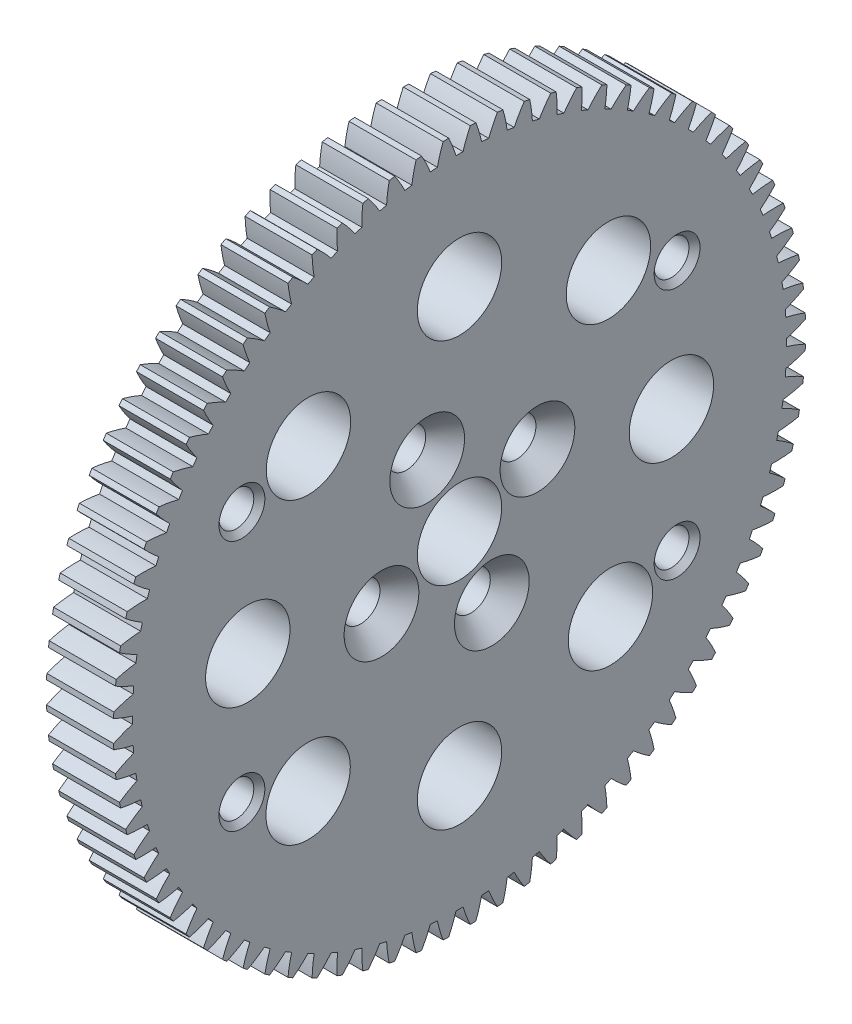
from build123d import *

# Parameters (mm, degrees)
SKETCH1_R                                      = 4
SKETCH1_R_2                                    = 1.75
BOSS_EXTRUDE1_DEPTH                            = 3.175
M4X0_7_TAPPED_HOLE1_AT_2_COUNT                 = 2
M4X0_7_TAPPED_HOLE1_AT_2_PITCH                 = 23.8125
M4X0_7_TAPPED_HOLE1_AT_3_COUNT                 = 2
M4X0_7_TAPPED_HOLE1_AT_3_PITCH                 = 41.244459855
M4X0_7_TAPPED_HOLE1_AT_4_COUNT                 = 2
M4X0_7_TAPPED_HOLE1_AT_4_PITCH                 = 47.625
CSK_FOR_6_FLAT_HEAD_MACHINE_SCREW1_D           = 3.6576
CSK_FOR_6_FLAT_HEAD_MACHINE_SCREW1_CSINK_D     = 7.0866
CSK_FOR_6_FLAT_HEAD_MACHINE_SCREW1_CSINK_ANGLE = 82


with BuildPart() as part:
    # Sketch1 → Boss-Extrude1 (new, symmetric)
    with BuildSketch(Plane(origin=(0, 0, 0), x_dir=(0, -1, 0), z_dir=(-1, 0, 0))):
        with BuildLine():
            ThreePointArc((-32.540485036, -4.117867604), (-31.611759802, -4.35271874), (-30.668071435, -4.517454533))
            ThreePointArc((-30.668071435, -4.517454533), (-30.61735087, -4.849311982), (-30.563039402, -5.180600688))
            ThreePointArc((-30.563039402, -5.180600688), (-31.409634214, -5.62888948), (-32.220331407, -6.139238063))
            ThreePointArc((-32.220331407, -6.139238063), (-32.169757197, -6.398962562), (-32.117089412, -6.658270623))
            ThreePointArc((-32.117089412, -6.658270623), (-31.17280092, -6.819530849), (-30.219096608, -6.909717881))
            ThreePointArc((-30.219096608, -6.909717881), (-30.142495162, -7.236572834), (-30.062358507, -7.562579059))
            ThreePointArc((-30.062358507, -7.562579059), (-30.871171216, -8.075908989), (-31.639327812, -8.648290907))
            ThreePointArc((-31.639327812, -8.648290907), (-31.568531756, -8.903246756), (-31.495681252, -9.15762319))
            ThreePointArc((-31.495681252, -9.15762319), (-30.541651355, -9.244298283), (-29.583811002, -9.25938052))
            ThreePointArc((-29.583811002, -9.25938052), (-29.481800949, -9.579217809), (-29.376333174, -9.897931615))
            ThreePointArc((-29.376333174, -9.897931615), (-30.142377181, -10.473137835), (-30.863257239, -11.104024162))
            ThreePointArc((-30.863257239, -11.104024162), (-30.772675818, -11.352639472), (-30.680091743, -11.600515964))
            ThreePointArc((-30.680091743, -11.600515964), (-29.722202353, -11.612071544), (-28.766131363, -11.551955999))
            ThreePointArc((-28.766131363, -11.551955999), (-28.639341628, -11.86280372), (-28.509192978, -12.172260132))
            ThreePointArc((-28.509192978, -12.172260132), (-29.227745368, -12.805796303), (-29.896904422, -13.491297415))
            ThreePointArc((-29.896904422, -13.491297415), (-29.787096101, -13.732039391), (-29.675349267, -13.9718877))
            ThreePointArc((-29.675349267, -13.9718877), (-28.719506089, -13.908252522), (-27.771098959, -13.773309829))
            ThreePointArc((-27.771098959, -13.773309829), (-27.620311243, -14.073251501), (-27.466284128, -14.371542617))
            ThreePointArc((-27.466284128, -14.371542617), (-28.132914785, -15.059502778), (-28.746227248, -15.795392334))
            ThreePointArc((-28.746227248, -15.795392334), (-28.617869032, -16.026776721), (-28.487648394, -16.257118102))
            ThreePointArc((-28.487648394, -16.257118102), (-27.53974452, -16.118684499), (-26.604848494, -15.909746623))
            ThreePointArc((-26.604848494, -15.909746623), (-26.430992455, -16.196933008), (-26.254036502, -16.482219763))
            ThreePointArc((-26.254036502, -16.482219763), (-26.864635428, -17.220362411), (-27.418320024, -18.002103406))
            ThreePointArc((-27.418320024, -18.002103406), (-27.272203284, -18.222703643), (-27.124311696, -18.442117965))
            ThreePointArc((-27.124311696, -18.442117965), (-26.190191269, -18.229739426), (-25.274570292, -17.948094538))
            ThreePointArc((-25.274570292, -17.948094538), (-25.078717809, -18.220755036), (-24.879924011, -18.491278544))
            ThreePointArc((-24.879924011, -18.491278544), (-25.430726659, -19.275052784), (-25.921369739, -20.097825525))
            ThreePointArc((-25.921369739, -20.097825525), (-25.758395333, -20.306281537), (-25.593744596, -20.513416038))
            ThreePointArc((-25.593744596, -20.513416038), (-24.679166779, -20.228401947), (-23.788465959, -19.875786483))
            ThreePointArc((-23.788465959, -19.875786483), (-23.571824528, -20.13224005), (-23.352418516, -20.386332443))
            ThreePointArc((-23.352418516, -20.386332443), (-23.840029005, -21.210906046), (-24.26460559, -22.069637866))
            ThreePointArc((-24.26460559, -22.069637866), (-24.085778309, -22.264664453), (-23.905383551, -22.458242079))
            ThreePointArc((-23.905383551, -22.458242079), (-23.015987019, -22.102349643), (-22.155697823, -21.680937594))
            ThreePointArc((-22.155697823, -21.680937594), (-21.91960311, -21.91960311), (-21.680937594, -22.155697823))
            ThreePointArc((-21.680937594, -22.155697823), (-22.102349643, -23.015987019), (-22.458242079, -23.905383551))
            ThreePointArc((-22.458242079, -23.905383551), (-22.264664453, -24.085778309), (-22.069637866, -24.26460559))
            ThreePointArc((-22.069637866, -24.26460559), (-21.210906046, -23.840029005), (-20.386332443, -23.352418516))
            ThreePointArc((-20.386332443, -23.352418516), (-20.13224005, -23.571824528), (-19.875786483, -23.788465959))
            ThreePointArc((-19.875786483, -23.788465959), (-20.228401947, -24.679166779), (-20.513416038, -25.593744596))
            ThreePointArc((-20.513416038, -25.593744596), (-20.306281537, -25.758395333), (-20.097825525, -25.921369739))
            ThreePointArc((-20.097825525, -25.921369739), (-19.275052784, -25.430726659), (-18.491278544, -24.879924011))
            ThreePointArc((-18.491278544, -24.879924011), (-18.220755036, -25.078717809), (-17.948094538, -25.274570292))
            ThreePointArc((-17.948094538, -25.274570292), (-18.229739426, -26.190191269), (-18.442117965, -27.124311696))
            ThreePointArc((-18.442117965, -27.124311696), (-18.222703643, -27.272203284), (-18.002103406, -27.418320024))
            ThreePointArc((-18.002103406, -27.418320024), (-17.220362411, -26.864635428), (-16.482219763, -26.254036502))
            ThreePointArc((-16.482219763, -26.254036502), (-16.196933008, -26.430992455), (-15.909746623, -26.604848494))
            ThreePointArc((-15.909746623, -26.604848494), (-16.118684499, -27.53974452), (-16.257118102, -28.487648394))
            ThreePointArc((-16.257118102, -28.487648394), (-16.026776721, -28.617869032), (-15.795392334, -28.746227248))
            ThreePointArc((-15.795392334, -28.746227248), (-15.059502778, -28.132914785), (-14.371542617, -27.466284128))
            ThreePointArc((-14.371542617, -27.466284128), (-14.073251501, -27.620311243), (-13.773309829, -27.771098959))
            ThreePointArc((-13.773309829, -27.771098959), (-13.908252522, -28.719506089), (-13.9718877, -29.675349267))
            ThreePointArc((-13.9718877, -29.675349267), (-13.732039391, -29.787096101), (-13.491297415, -29.896904422))
            ThreePointArc((-13.491297415, -29.896904422), (-12.805796303, -29.227745368), (-12.172260132, -28.509192978))
            ThreePointArc((-12.172260132, -28.509192978), (-11.86280372, -28.639341628), (-11.551955999, -28.766131363))
            ThreePointArc((-11.551955999, -28.766131363), (-11.612071544, -29.722202353), (-11.600515964, -30.680091743))
            ThreePointArc((-11.600515964, -30.680091743), (-11.352639472, -30.772675818), (-11.104024162, -30.863257239))
            ThreePointArc((-11.104024162, -30.863257239), (-10.473137835, -30.142377181), (-9.897931615, -29.376333174))
            ThreePointArc((-9.897931615, -29.376333174), (-9.579217809, -29.481800949), (-9.25938052, -29.583811002))
            ThreePointArc((-9.25938052, -29.583811002), (-9.244298283, -30.541651355), (-9.15762319, -31.495681252))
            ThreePointArc((-9.15762319, -31.495681252), (-8.903246756, -31.568531756), (-8.648290907, -31.639327812))
            ThreePointArc((-8.648290907, -31.639327812), (-8.075908989, -30.871171216), (-7.562579059, -30.062358507))
            ThreePointArc((-7.562579059, -30.062358507), (-7.236572834, -30.142495162), (-6.909717881, -30.219096608))
            ThreePointArc((-6.909717881, -30.219096608), (-6.819530849, -31.17280092), (-6.658270623, -32.117089412))
            ThreePointArc((-6.658270623, -32.117089412), (-6.398962562, -32.169757197), (-6.139238063, -32.220331407))
            ThreePointArc((-6.139238063, -32.220331407), (-5.62888948, -31.409634214), (-5.180600688, -30.563039402))
            ThreePointArc((-5.180600688, -30.563039402), (-4.849311982, -30.61735087), (-4.517454533, -30.668071435))
            ThreePointArc((-4.517454533, -30.668071435), (-4.35271874, -31.611759802), (-4.117867604, -32.540485036))
            ThreePointArc((-4.117867604, -32.540485036), (-3.855226637, -32.572645388), (-3.592334775, -32.602685946))
            ThreePointArc((-3.592334775, -32.602685946), (-3.147165994, -31.754446373), (-2.76668219, -30.875288997))
            ThreePointArc((-2.76668219, -30.875288997), (-2.432153508, -30.903440428), (-2.097339576, -30.927967403))
            ThreePointArc((-2.097339576, -30.927967403), (-1.859070673, -31.855821673), (-1.552076562, -32.763257749))
            ThreePointArc((-1.552076562, -32.763257749), (-1.287721957, -32.774712389), (-1.023283548, -32.784034083))
            ThreePointArc((-1.023283548, -32.784034083), (-0.646039184, -31.90348181), (-0.335706178, -30.997182168))
            ThreePointArc((-0.335706178, -30.997182168), (0, -30.999), (0.335706178, -30.997182168))
            ThreePointArc((0.335706178, -30.997182168), (0.646039184, -31.90348181), (1.023283548, -32.784034083))
            ThreePointArc((1.023283548, -32.784034083), (1.287721957, -32.774712389), (1.552076562, -32.763257749))
            ThreePointArc((1.552076562, -32.763257749), (1.859070673, -31.855821673), (2.097339576, -30.927967403))
            ThreePointArc((2.097339576, -30.927967403), (2.432153508, -30.903440428), (2.76668219, -30.875288997))
            ThreePointArc((2.76668219, -30.875288997), (3.147165994, -31.754446373), (3.592334775, -32.602685946))
            ThreePointArc((3.592334775, -32.602685946), (3.855226637, -32.572645388), (4.117867604, -32.540485036))
            ThreePointArc((4.117867604, -32.540485036), (4.35271874, -31.611759802), (4.517454533, -30.668071435))
            ThreePointArc((4.517454533, -30.668071435), (4.849311982, -30.61735087), (5.180600688, -30.563039402))
            ThreePointArc((5.180600688, -30.563039402), (5.62888948, -31.409634214), (6.139238063, -32.220331407))
            ThreePointArc((6.139238063, -32.220331407), (6.398962562, -32.169757197), (6.658270623, -32.117089412))
            ThreePointArc((6.658270623, -32.117089412), (6.819530849, -31.17280092), (6.909717881, -30.219096608))
            ThreePointArc((6.909717881, -30.219096608), (7.236572834, -30.142495162), (7.562579059, -30.062358507))
            ThreePointArc((7.562579059, -30.062358507), (8.075908989, -30.871171216), (8.648290907, -31.639327812))
            ThreePointArc((8.648290907, -31.639327812), (8.903246756, -31.568531756), (9.15762319, -31.495681252))
            ThreePointArc((9.15762319, -31.495681252), (9.244298283, -30.541651355), (9.25938052, -29.583811002))
            ThreePointArc((9.25938052, -29.583811002), (9.579217809, -29.481800949), (9.897931615, -29.376333174))
            ThreePointArc((9.897931615, -29.376333174), (10.473137835, -30.142377181), (11.104024162, -30.863257239))
            ThreePointArc((11.104024162, -30.863257239), (11.352639472, -30.772675818), (11.600515964, -30.680091743))
            ThreePointArc((11.600515964, -30.680091743), (11.612071544, -29.722202353), (11.551955999, -28.766131363))
            ThreePointArc((11.551955999, -28.766131363), (11.86280372, -28.639341628), (12.172260132, -28.509192978))
            ThreePointArc((12.172260132, -28.509192978), (12.805796303, -29.227745368), (13.491297415, -29.896904422))
            ThreePointArc((13.491297415, -29.896904422), (13.732039391, -29.787096101), (13.9718877, -29.675349267))
            ThreePointArc((13.9718877, -29.675349267), (13.908252522, -28.719506089), (13.773309829, -27.771098959))
            ThreePointArc((13.773309829, -27.771098959), (14.073251501, -27.620311243), (14.371542617, -27.466284128))
            ThreePointArc((14.371542617, -27.466284128), (15.059502778, -28.132914785), (15.795392334, -28.746227248))
            ThreePointArc((15.795392334, -28.746227248), (16.026776721, -28.617869032), (16.257118102, -28.487648394))
            ThreePointArc((16.257118102, -28.487648394), (16.118684499, -27.53974452), (15.909746623, -26.604848494))
            ThreePointArc((15.909746623, -26.604848494), (16.196933008, -26.430992455), (16.482219763, -26.254036502))
            ThreePointArc((16.482219763, -26.254036502), (17.220362411, -26.864635428), (18.002103406, -27.418320024))
            ThreePointArc((18.002103406, -27.418320024), (18.222703643, -27.272203284), (18.442117965, -27.124311696))
            ThreePointArc((18.442117965, -27.124311696), (18.229739426, -26.190191269), (17.948094538, -25.274570292))
            ThreePointArc((17.948094538, -25.274570292), (18.220755036, -25.078717809), (18.491278544, -24.879924011))
            ThreePointArc((18.491278544, -24.879924011), (19.275052784, -25.430726659), (20.097825525, -25.921369739))
            ThreePointArc((20.097825525, -25.921369739), (20.306281537, -25.758395333), (20.513416038, -25.593744596))
            ThreePointArc((20.513416038, -25.593744596), (20.228401947, -24.679166779), (19.875786483, -23.788465959))
            ThreePointArc((19.875786483, -23.788465959), (20.13224005, -23.571824528), (20.386332443, -23.352418516))
            ThreePointArc((20.386332443, -23.352418516), (21.210906046, -23.840029005), (22.069637866, -24.26460559))
            ThreePointArc((22.069637866, -24.26460559), (22.264664453, -24.085778309), (22.458242079, -23.905383551))
            ThreePointArc((22.458242079, -23.905383551), (22.102349643, -23.015987019), (21.680937594, -22.155697823))
            ThreePointArc((21.680937594, -22.155697823), (21.91960311, -21.91960311), (22.155697823, -21.680937594))
            ThreePointArc((22.155697823, -21.680937594), (23.015987019, -22.102349643), (23.905383551, -22.458242079))
            ThreePointArc((23.905383551, -22.458242079), (24.085778309, -22.264664453), (24.26460559, -22.069637866))
            ThreePointArc((24.26460559, -22.069637866), (23.840029005, -21.210906046), (23.352418516, -20.386332443))
            ThreePointArc((23.352418516, -20.386332443), (23.571824528, -20.13224005), (23.788465959, -19.875786483))
            ThreePointArc((23.788465959, -19.875786483), (24.679166779, -20.228401947), (25.593744596, -20.513416038))
            ThreePointArc((25.593744596, -20.513416038), (25.758395333, -20.306281537), (25.921369739, -20.097825525))
            ThreePointArc((25.921369739, -20.097825525), (25.430726659, -19.275052784), (24.879924011, -18.491278544))
            ThreePointArc((24.879924011, -18.491278544), (25.078717809, -18.220755036), (25.274570292, -17.948094538))
            ThreePointArc((25.274570292, -17.948094538), (26.190191269, -18.229739426), (27.124311696, -18.442117965))
            ThreePointArc((27.124311696, -18.442117965), (27.272203284, -18.222703643), (27.418320024, -18.002103406))
            ThreePointArc((27.418320024, -18.002103406), (26.864635428, -17.220362411), (26.254036502, -16.482219763))
            ThreePointArc((26.254036502, -16.482219763), (26.430992455, -16.196933008), (26.604848494, -15.909746623))
            ThreePointArc((26.604848494, -15.909746623), (27.53974452, -16.118684499), (28.487648394, -16.257118102))
            ThreePointArc((28.487648394, -16.257118102), (28.617869032, -16.026776721), (28.746227248, -15.795392334))
            ThreePointArc((28.746227248, -15.795392334), (28.132914785, -15.059502778), (27.466284128, -14.371542617))
            ThreePointArc((27.466284128, -14.371542617), (27.620311243, -14.073251501), (27.771098959, -13.773309829))
            ThreePointArc((27.771098959, -13.773309829), (28.719506089, -13.908252522), (29.675349267, -13.9718877))
            ThreePointArc((29.675349267, -13.9718877), (29.787096101, -13.732039391), (29.896904422, -13.491297415))
            ThreePointArc((29.896904422, -13.491297415), (29.227745368, -12.805796303), (28.509192978, -12.172260132))
            ThreePointArc((28.509192978, -12.172260132), (28.639341628, -11.86280372), (28.766131363, -11.551955999))
            ThreePointArc((28.766131363, -11.551955999), (29.722202353, -11.612071544), (30.680091743, -11.600515964))
            ThreePointArc((30.680091743, -11.600515964), (30.772675818, -11.352639472), (30.863257239, -11.104024162))
            ThreePointArc((30.863257239, -11.104024162), (30.142377181, -10.473137835), (29.376333174, -9.897931615))
            ThreePointArc((29.376333174, -9.897931615), (29.481800949, -9.579217809), (29.583811002, -9.25938052))
            ThreePointArc((29.583811002, -9.25938052), (30.541651355, -9.244298283), (31.495681252, -9.15762319))
            ThreePointArc((31.495681252, -9.15762319), (31.568531756, -8.903246756), (31.639327812, -8.648290907))
            ThreePointArc((31.639327812, -8.648290907), (30.871171216, -8.075908989), (30.062358507, -7.562579059))
            ThreePointArc((30.062358507, -7.562579059), (30.142495162, -7.236572834), (30.219096608, -6.909717881))
            ThreePointArc((30.219096608, -6.909717881), (31.17280092, -6.819530849), (32.117089412, -6.658270623))
            ThreePointArc((32.117089412, -6.658270623), (32.169757197, -6.398962562), (32.220331407, -6.139238063))
            ThreePointArc((32.220331407, -6.139238063), (31.409634214, -5.62888948), (30.563039402, -5.180600688))
            ThreePointArc((30.563039402, -5.180600688), (30.61735087, -4.849311982), (30.668071435, -4.517454533))
            ThreePointArc((30.668071435, -4.517454533), (31.611759802, -4.35271874), (32.540485036, -4.117867604))
            ThreePointArc((32.540485036, -4.117867604), (32.572645388, -3.855226637), (32.602685946, -3.592334775))
            ThreePointArc((32.602685946, -3.592334775), (31.754446373, -3.147165994), (30.875288997, -2.76668219))
            ThreePointArc((30.875288997, -2.76668219), (30.903440428, -2.432153508), (30.927967403, -2.097339576))
            ThreePointArc((30.927967403, -2.097339576), (31.855821673, -1.859070673), (32.763257749, -1.552076562))
            ThreePointArc((32.763257749, -1.552076562), (32.774712389, -1.287721957), (32.784034083, -1.023283548))
            ThreePointArc((32.784034083, -1.023283548), (31.90348181, -0.646039184), (30.997182168, -0.335706178))
            ThreePointArc((30.997182168, -0.335706178), (30.999, 0), (30.997182168, 0.335706178))
            ThreePointArc((30.997182168, 0.335706178), (31.90348181, 0.646039184), (32.784034083, 1.023283548))
            ThreePointArc((32.784034083, 1.023283548), (32.774712389, 1.287721957), (32.763257749, 1.552076562))
            ThreePointArc((32.763257749, 1.552076562), (31.855821673, 1.859070673), (30.927967403, 2.097339576))
            ThreePointArc((30.927967403, 2.097339576), (30.903440428, 2.432153508), (30.875288997, 2.76668219))
            ThreePointArc((30.875288997, 2.76668219), (31.754446373, 3.147165994), (32.602685946, 3.592334775))
            ThreePointArc((32.602685946, 3.592334775), (32.572645388, 3.855226637), (32.540485036, 4.117867604))
            ThreePointArc((32.540485036, 4.117867604), (31.611759802, 4.35271874), (30.668071435, 4.517454533))
            ThreePointArc((30.668071435, 4.517454533), (30.61735087, 4.849311982), (30.563039402, 5.180600688))
            ThreePointArc((30.563039402, 5.180600688), (31.409634214, 5.62888948), (32.220331407, 6.139238063))
            ThreePointArc((32.220331407, 6.139238063), (32.169757197, 6.398962562), (32.117089412, 6.658270623))
            ThreePointArc((32.117089412, 6.658270623), (31.17280092, 6.819530849), (30.219096608, 6.909717881))
            ThreePointArc((30.219096608, 6.909717881), (30.142495162, 7.236572834), (30.062358507, 7.562579059))
            ThreePointArc((30.062358507, 7.562579059), (30.871171216, 8.075908989), (31.639327812, 8.648290907))
            ThreePointArc((31.639327812, 8.648290907), (31.568531756, 8.903246756), (31.495681252, 9.15762319))
            ThreePointArc((31.495681252, 9.15762319), (30.541651355, 9.244298283), (29.583811002, 9.25938052))
            ThreePointArc((29.583811002, 9.25938052), (29.481800949, 9.579217809), (29.376333174, 9.897931615))
            ThreePointArc((29.376333174, 9.897931615), (30.142377181, 10.473137835), (30.863257239, 11.104024162))
            ThreePointArc((30.863257239, 11.104024162), (30.772675818, 11.352639472), (30.680091743, 11.600515964))
            ThreePointArc((30.680091743, 11.600515964), (29.722202353, 11.612071544), (28.766131363, 11.551955999))
            ThreePointArc((28.766131363, 11.551955999), (28.639341628, 11.86280372), (28.509192978, 12.172260132))
            ThreePointArc((28.509192978, 12.172260132), (29.227745368, 12.805796303), (29.896904422, 13.491297415))
            ThreePointArc((29.896904422, 13.491297415), (29.787096101, 13.732039391), (29.675349267, 13.9718877))
            ThreePointArc((29.675349267, 13.9718877), (28.719506089, 13.908252522), (27.771098959, 13.773309829))
            ThreePointArc((27.771098959, 13.773309829), (27.620311243, 14.073251501), (27.466284128, 14.371542617))
            ThreePointArc((27.466284128, 14.371542617), (28.132914785, 15.059502778), (28.746227248, 15.795392334))
            ThreePointArc((28.746227248, 15.795392334), (28.617869032, 16.026776721), (28.487648394, 16.257118102))
            ThreePointArc((28.487648394, 16.257118102), (27.53974452, 16.118684499), (26.604848494, 15.909746623))
            ThreePointArc((26.604848494, 15.909746623), (26.430992455, 16.196933008), (26.254036502, 16.482219763))
            ThreePointArc((26.254036502, 16.482219763), (26.864635428, 17.220362411), (27.418320024, 18.002103406))
            ThreePointArc((27.418320024, 18.002103406), (27.272203284, 18.222703643), (27.124311696, 18.442117965))
            ThreePointArc((27.124311696, 18.442117965), (26.190191269, 18.229739426), (25.274570292, 17.948094538))
            ThreePointArc((25.274570292, 17.948094538), (25.078717809, 18.220755036), (24.879924011, 18.491278544))
            ThreePointArc((24.879924011, 18.491278544), (25.430726659, 19.275052784), (25.921369739, 20.097825525))
            ThreePointArc((25.921369739, 20.097825525), (25.758395333, 20.306281537), (25.593744596, 20.513416038))
            ThreePointArc((25.593744596, 20.513416038), (24.679166779, 20.228401947), (23.788465959, 19.875786483))
            ThreePointArc((23.788465959, 19.875786483), (23.571824528, 20.13224005), (23.352418516, 20.386332443))
            ThreePointArc((23.352418516, 20.386332443), (23.840029005, 21.210906046), (24.26460559, 22.069637866))
            ThreePointArc((24.26460559, 22.069637866), (24.085778309, 22.264664453), (23.905383551, 22.458242079))
            ThreePointArc((23.905383551, 22.458242079), (23.015987019, 22.102349643), (22.155697823, 21.680937594))
            ThreePointArc((22.155697823, 21.680937594), (21.91960311, 21.91960311), (21.680937594, 22.155697823))
            ThreePointArc((21.680937594, 22.155697823), (22.102349643, 23.015987019), (22.458242079, 23.905383551))
            ThreePointArc((22.458242079, 23.905383551), (22.264664453, 24.085778309), (22.069637866, 24.26460559))
            ThreePointArc((22.069637866, 24.26460559), (21.210906046, 23.840029005), (20.386332443, 23.352418516))
            ThreePointArc((20.386332443, 23.352418516), (20.13224005, 23.571824528), (19.875786483, 23.788465959))
            ThreePointArc((19.875786483, 23.788465959), (20.228401947, 24.679166779), (20.513416038, 25.593744596))
            ThreePointArc((20.513416038, 25.593744596), (20.306281537, 25.758395333), (20.097825525, 25.921369739))
            ThreePointArc((20.097825525, 25.921369739), (19.275052784, 25.430726659), (18.491278544, 24.879924011))
            ThreePointArc((18.491278544, 24.879924011), (18.220755036, 25.078717809), (17.948094538, 25.274570292))
            ThreePointArc((17.948094538, 25.274570292), (18.229739426, 26.190191269), (18.442117965, 27.124311696))
            ThreePointArc((18.442117965, 27.124311696), (18.222703643, 27.272203284), (18.002103406, 27.418320024))
            ThreePointArc((18.002103406, 27.418320024), (17.220362411, 26.864635428), (16.482219763, 26.254036502))
            ThreePointArc((16.482219763, 26.254036502), (16.196933008, 26.430992455), (15.909746623, 26.604848494))
            ThreePointArc((15.909746623, 26.604848494), (16.118684499, 27.53974452), (16.257118102, 28.487648394))
            ThreePointArc((16.257118102, 28.487648394), (16.026776721, 28.617869032), (15.795392334, 28.746227248))
            ThreePointArc((15.795392334, 28.746227248), (15.059502778, 28.132914785), (14.371542617, 27.466284128))
            ThreePointArc((14.371542617, 27.466284128), (14.073251501, 27.620311243), (13.773309829, 27.771098959))
            ThreePointArc((13.773309829, 27.771098959), (13.908252522, 28.719506089), (13.9718877, 29.675349267))
            ThreePointArc((13.9718877, 29.675349267), (13.732039391, 29.787096101), (13.491297415, 29.896904422))
            ThreePointArc((13.491297415, 29.896904422), (12.805796303, 29.227745368), (12.172260132, 28.509192978))
            ThreePointArc((12.172260132, 28.509192978), (11.86280372, 28.639341628), (11.551955999, 28.766131363))
            ThreePointArc((11.551955999, 28.766131363), (11.612071544, 29.722202353), (11.600515964, 30.680091743))
            ThreePointArc((11.600515964, 30.680091743), (11.352639472, 30.772675818), (11.104024162, 30.863257239))
            ThreePointArc((11.104024162, 30.863257239), (10.473137835, 30.142377181), (9.897931615, 29.376333174))
            ThreePointArc((9.897931615, 29.376333174), (9.579217809, 29.481800949), (9.25938052, 29.583811002))
            ThreePointArc((9.25938052, 29.583811002), (9.244298283, 30.541651355), (9.15762319, 31.495681252))
            ThreePointArc((9.15762319, 31.495681252), (8.903246756, 31.568531756), (8.648290907, 31.639327812))
            ThreePointArc((8.648290907, 31.639327812), (8.075908989, 30.871171216), (7.562579059, 30.062358507))
            ThreePointArc((7.562579059, 30.062358507), (7.236572834, 30.142495162), (6.909717881, 30.219096608))
            ThreePointArc((6.909717881, 30.219096608), (6.819530849, 31.17280092), (6.658270623, 32.117089412))
            ThreePointArc((6.658270623, 32.117089412), (6.398962562, 32.169757197), (6.139238063, 32.220331407))
            ThreePointArc((6.139238063, 32.220331407), (5.62888948, 31.409634214), (5.180600688, 30.563039402))
            ThreePointArc((5.180600688, 30.563039402), (4.849311982, 30.61735087), (4.517454533, 30.668071435))
            ThreePointArc((4.517454533, 30.668071435), (4.35271874, 31.611759802), (4.117867604, 32.540485036))
            ThreePointArc((4.117867604, 32.540485036), (3.855226637, 32.572645388), (3.592334775, 32.602685946))
            ThreePointArc((3.592334775, 32.602685946), (3.147165994, 31.754446373), (2.76668219, 30.875288997))
            ThreePointArc((2.76668219, 30.875288997), (2.432153508, 30.903440428), (2.097339576, 30.927967403))
            ThreePointArc((2.097339576, 30.927967403), (1.859070673, 31.855821673), (1.552076562, 32.763257749))
            ThreePointArc((1.552076562, 32.763257749), (1.287721957, 32.774712389), (1.023283548, 32.784034083))
            ThreePointArc((1.023283548, 32.784034083), (0.646039184, 31.90348181), (0.335706178, 30.997182168))
            ThreePointArc((0.335706178, 30.997182168), (0, 30.999), (-0.335706178, 30.997182168))
            ThreePointArc((-0.335706178, 30.997182168), (-0.646039184, 31.90348181), (-1.023283548, 32.784034083))
            ThreePointArc((-1.023283548, 32.784034083), (-1.287721957, 32.774712389), (-1.552076562, 32.763257749))
            ThreePointArc((-1.552076562, 32.763257749), (-1.859070673, 31.855821673), (-2.097339576, 30.927967403))
            ThreePointArc((-2.097339576, 30.927967403), (-2.432153508, 30.903440428), (-2.76668219, 30.875288997))
            ThreePointArc((-2.76668219, 30.875288997), (-3.147165994, 31.754446373), (-3.592334775, 32.602685946))
            ThreePointArc((-3.592334775, 32.602685946), (-3.855226637, 32.572645388), (-4.117867604, 32.540485036))
            ThreePointArc((-4.117867604, 32.540485036), (-4.35271874, 31.611759802), (-4.517454533, 30.668071435))
            ThreePointArc((-4.517454533, 30.668071435), (-4.849311982, 30.61735087), (-5.180600688, 30.563039402))
            ThreePointArc((-5.180600688, 30.563039402), (-5.62888948, 31.409634214), (-6.139238063, 32.220331407))
            ThreePointArc((-6.139238063, 32.220331407), (-6.398962562, 32.169757197), (-6.658270623, 32.117089412))
            ThreePointArc((-6.658270623, 32.117089412), (-6.819530849, 31.17280092), (-6.909717881, 30.219096608))
            ThreePointArc((-6.909717881, 30.219096608), (-7.236572834, 30.142495162), (-7.562579059, 30.062358507))
            ThreePointArc((-7.562579059, 30.062358507), (-8.075908989, 30.871171216), (-8.648290907, 31.639327812))
            ThreePointArc((-8.648290907, 31.639327812), (-8.903246756, 31.568531756), (-9.15762319, 31.495681252))
            ThreePointArc((-9.15762319, 31.495681252), (-9.244298283, 30.541651355), (-9.25938052, 29.583811002))
            ThreePointArc((-9.25938052, 29.583811002), (-9.579217809, 29.481800949), (-9.897931615, 29.376333174))
            ThreePointArc((-9.897931615, 29.376333174), (-10.473137835, 30.142377181), (-11.104024162, 30.863257239))
            ThreePointArc((-11.104024162, 30.863257239), (-11.352639472, 30.772675818), (-11.600515964, 30.680091743))
            ThreePointArc((-11.600515964, 30.680091743), (-11.612071544, 29.722202353), (-11.551955999, 28.766131363))
            ThreePointArc((-11.551955999, 28.766131363), (-11.86280372, 28.639341628), (-12.172260132, 28.509192978))
            ThreePointArc((-12.172260132, 28.509192978), (-12.805796303, 29.227745368), (-13.491297415, 29.896904422))
            ThreePointArc((-13.491297415, 29.896904422), (-13.732039391, 29.787096101), (-13.9718877, 29.675349267))
            ThreePointArc((-13.9718877, 29.675349267), (-13.908252522, 28.719506089), (-13.773309829, 27.771098959))
            ThreePointArc((-13.773309829, 27.771098959), (-14.073251501, 27.620311243), (-14.371542617, 27.466284128))
            ThreePointArc((-14.371542617, 27.466284128), (-15.059502778, 28.132914785), (-15.795392334, 28.746227248))
            ThreePointArc((-15.795392334, 28.746227248), (-16.026776721, 28.617869032), (-16.257118102, 28.487648394))
            ThreePointArc((-16.257118102, 28.487648394), (-16.118684499, 27.53974452), (-15.909746623, 26.604848494))
            ThreePointArc((-15.909746623, 26.604848494), (-16.196933008, 26.430992455), (-16.482219763, 26.254036502))
            ThreePointArc((-16.482219763, 26.254036502), (-17.220362411, 26.864635428), (-18.002103406, 27.418320024))
            ThreePointArc((-18.002103406, 27.418320024), (-18.222703643, 27.272203284), (-18.442117965, 27.124311696))
            ThreePointArc((-18.442117965, 27.124311696), (-18.229739426, 26.190191269), (-17.948094538, 25.274570292))
            ThreePointArc((-17.948094538, 25.274570292), (-18.220755036, 25.078717809), (-18.491278544, 24.879924011))
            ThreePointArc((-18.491278544, 24.879924011), (-19.275052784, 25.430726659), (-20.097825525, 25.921369739))
            ThreePointArc((-20.097825525, 25.921369739), (-20.306281537, 25.758395333), (-20.513416038, 25.593744596))
            ThreePointArc((-20.513416038, 25.593744596), (-20.228401947, 24.679166779), (-19.875786483, 23.788465959))
            ThreePointArc((-19.875786483, 23.788465959), (-20.13224005, 23.571824528), (-20.386332443, 23.352418516))
            ThreePointArc((-20.386332443, 23.352418516), (-21.210906046, 23.840029005), (-22.069637866, 24.26460559))
            ThreePointArc((-22.069637866, 24.26460559), (-22.264664453, 24.085778309), (-22.458242079, 23.905383551))
            ThreePointArc((-22.458242079, 23.905383551), (-22.102349643, 23.015987019), (-21.680937594, 22.155697823))
            ThreePointArc((-21.680937594, 22.155697823), (-21.91960311, 21.91960311), (-22.155697823, 21.680937594))
            ThreePointArc((-22.155697823, 21.680937594), (-23.015987019, 22.102349643), (-23.905383551, 22.458242079))
            ThreePointArc((-23.905383551, 22.458242079), (-24.085778309, 22.264664453), (-24.26460559, 22.069637866))
            ThreePointArc((-24.26460559, 22.069637866), (-23.840029005, 21.210906046), (-23.352418516, 20.386332443))
            ThreePointArc((-23.352418516, 20.386332443), (-23.571824528, 20.13224005), (-23.788465959, 19.875786483))
            ThreePointArc((-23.788465959, 19.875786483), (-24.679166779, 20.228401947), (-25.593744596, 20.513416038))
            ThreePointArc((-25.593744596, 20.513416038), (-25.758395333, 20.306281537), (-25.921369739, 20.097825525))
            ThreePointArc((-25.921369739, 20.097825525), (-25.430726659, 19.275052784), (-24.879924011, 18.491278544))
            ThreePointArc((-24.879924011, 18.491278544), (-25.078717809, 18.220755036), (-25.274570292, 17.948094538))
            ThreePointArc((-25.274570292, 17.948094538), (-26.190191269, 18.229739426), (-27.124311696, 18.442117965))
            ThreePointArc((-27.124311696, 18.442117965), (-27.272203284, 18.222703643), (-27.418320024, 18.002103406))
            ThreePointArc((-27.418320024, 18.002103406), (-26.864635428, 17.220362411), (-26.254036502, 16.482219763))
            ThreePointArc((-26.254036502, 16.482219763), (-26.430992455, 16.196933008), (-26.604848494, 15.909746623))
            ThreePointArc((-26.604848494, 15.909746623), (-27.53974452, 16.118684499), (-28.487648394, 16.257118102))
            ThreePointArc((-28.487648394, 16.257118102), (-28.617869032, 16.026776721), (-28.746227248, 15.795392334))
            ThreePointArc((-28.746227248, 15.795392334), (-28.132914785, 15.059502778), (-27.466284128, 14.371542617))
            ThreePointArc((-27.466284128, 14.371542617), (-27.620311243, 14.073251501), (-27.771098959, 13.773309829))
            ThreePointArc((-27.771098959, 13.773309829), (-28.719506089, 13.908252522), (-29.675349267, 13.9718877))
            ThreePointArc((-29.675349267, 13.9718877), (-29.787096101, 13.732039391), (-29.896904422, 13.491297415))
            ThreePointArc((-29.896904422, 13.491297415), (-29.227745368, 12.805796303), (-28.509192978, 12.172260132))
            ThreePointArc((-28.509192978, 12.172260132), (-28.639341628, 11.86280372), (-28.766131363, 11.551955999))
            ThreePointArc((-28.766131363, 11.551955999), (-29.722202353, 11.612071544), (-30.680091743, 11.600515964))
            ThreePointArc((-30.680091743, 11.600515964), (-30.772675818, 11.352639472), (-30.863257239, 11.104024162))
            ThreePointArc((-30.863257239, 11.104024162), (-30.142377181, 10.473137835), (-29.376333174, 9.897931615))
            ThreePointArc((-29.376333174, 9.897931615), (-29.481800949, 9.579217809), (-29.583811002, 9.25938052))
            ThreePointArc((-29.583811002, 9.25938052), (-30.541651355, 9.244298283), (-31.495681252, 9.15762319))
            ThreePointArc((-31.495681252, 9.15762319), (-31.568531756, 8.903246756), (-31.639327812, 8.648290907))
            ThreePointArc((-31.639327812, 8.648290907), (-30.871171216, 8.075908989), (-30.062358507, 7.562579059))
            ThreePointArc((-30.062358507, 7.562579059), (-30.142495162, 7.236572834), (-30.219096608, 6.909717881))
            ThreePointArc((-30.219096608, 6.909717881), (-31.17280092, 6.819530849), (-32.117089412, 6.658270623))
            ThreePointArc((-32.117089412, 6.658270623), (-32.169757197, 6.398962562), (-32.220331407, 6.139238063))
            ThreePointArc((-32.220331407, 6.139238063), (-31.409634214, 5.62888948), (-30.563039402, 5.180600688))
            ThreePointArc((-30.563039402, 5.180600688), (-30.61735087, 4.849311982), (-30.668071435, 4.517454533))
            ThreePointArc((-30.668071435, 4.517454533), (-31.611759802, 4.35271874), (-32.540485036, 4.117867604))
            ThreePointArc((-32.540485036, 4.117867604), (-32.572645388, 3.855226637), (-32.602685946, 3.592334775))
            ThreePointArc((-32.602685946, 3.592334775), (-31.754446373, 3.147165994), (-30.875288997, 2.76668219))
            ThreePointArc((-30.875288997, 2.76668219), (-30.903440428, 2.432153508), (-30.927967403, 2.097339576))
            ThreePointArc((-30.927967403, 2.097339576), (-31.855821673, 1.859070673), (-32.763257749, 1.552076562))
            ThreePointArc((-32.763257749, 1.552076562), (-32.774712389, 1.287721957), (-32.784034083, 1.023283548))
            ThreePointArc((-32.784034083, 1.023283548), (-31.90348181, 0.646039184), (-30.997182168, 0.335706178))
            ThreePointArc((-30.997182168, 0.335706178), (-30.999, 0), (-30.997182168, -0.335706178))
            ThreePointArc((-30.997182168, -0.335706178), (-31.90348181, -0.646039184), (-32.784034083, -1.023283548))
            ThreePointArc((-32.784034083, -1.023283548), (-32.774712389, -1.287721957), (-32.763257749, -1.552076562))
            ThreePointArc((-32.763257749, -1.552076562), (-31.855821673, -1.859070673), (-30.927967403, -2.097339576))
            ThreePointArc((-30.927967403, -2.097339576), (-30.903440428, -2.432153508), (-30.875288997, -2.76668219))
            ThreePointArc((-30.875288997, -2.76668219), (-31.754446373, -3.147165994), (-32.602685946, -3.592334775))
            ThreePointArc((-32.602685946, -3.592334775), (-32.572645388, -3.855226637), (-32.540485036, -4.117867604))
        make_face()
        Circle(SKETCH1_R, mode=Mode.SUBTRACT)
        with Locations((3.061467459, 7.39103626)):
            Circle(SKETCH1_R_2, mode=Mode.SUBTRACT)
        with Locations((-20.084034083, 0)):
            Circle(SKETCH1_R, mode=Mode.SUBTRACT)
        with Locations((20.063257749, 0)):
            Circle(SKETCH1_R, mode=Mode.SUBTRACT)
        with Locations((0, -20.084034083)):
            Circle(SKETCH1_R, mode=Mode.SUBTRACT)
        with Locations((0, 20.063257749)):
            Circle(SKETCH1_R, mode=Mode.SUBTRACT)
        with Locations((-14.36634376, -14.112602443)):
            Circle(SKETCH1_R, mode=Mode.SUBTRACT)
        with Locations((14.14202094, -14.306921905)):
            Circle(SKETCH1_R, mode=Mode.SUBTRACT)
        with Locations((14.135100494, 14.348299993)):
            Circle(SKETCH1_R, mode=Mode.SUBTRACT)
        with Locations((-14.159703758, 14.315040904)):
            Circle(SKETCH1_R, mode=Mode.SUBTRACT)
        with Locations((-7.39103626, 3.061467459)):
            Circle(SKETCH1_R_2, mode=Mode.SUBTRACT)
        with Locations((7.39103626, -3.061467459)):
            Circle(SKETCH1_R_2, mode=Mode.SUBTRACT)
        with Locations((-3.061467459, -7.39103626)):
            Circle(SKETCH1_R_2, mode=Mode.SUBTRACT)
    extrude(amount=BOSS_EXTRUDE1_DEPTH, both=True)

    # Sketch5 → M4x0.7 Tapped Hole1 (revolve, cut)
    with BuildSketch(Plane(origin=(3.175, 11.90625, 20.622229928), x_dir=(0, 0, -1), z_dir=(0, 1, 0))):
        Polygon((0, 0), (0, 6.35), (2.175, 6.35), (1.65, 5.825), (1.65, 0.525), (2.175, 0), align=None)
    m4x0_7_tapped_hole1 = revolve(axis=Axis((9.525, 11.90625, 20.622229928), (-1, 0, 0)), mode=Mode.SUBTRACT)

    # M4x0.7 Tapped Hole1 at 2: M4x0.7 Tapped Hole1 ×2
    with Locations(*[(0, -i * M4X0_7_TAPPED_HOLE1_AT_2_PITCH, 0) for i in range(1, M4X0_7_TAPPED_HOLE1_AT_2_COUNT)]):
        add(m4x0_7_tapped_hole1, mode=Mode.SUBTRACT)

    # M4x0.7 Tapped Hole1 at 3: M4x0.7 Tapped Hole1 ×2
    with Locations(*[(0, 0, -i * M4X0_7_TAPPED_HOLE1_AT_3_PITCH) for i in range(1, M4X0_7_TAPPED_HOLE1_AT_3_COUNT)]):
        add(m4x0_7_tapped_hole1, mode=Mode.SUBTRACT)

    # M4x0.7 Tapped Hole1 at 4: M4x0.7 Tapped Hole1 ×2
    with Locations(*[Vector(0, -0.5000000000000026, -0.8660254037844373) * (i * M4X0_7_TAPPED_HOLE1_AT_4_PITCH) for i in range(1, M4X0_7_TAPPED_HOLE1_AT_4_COUNT)]):
        add(m4x0_7_tapped_hole1, mode=Mode.SUBTRACT)

    # CSK for _6 Flat Head Machine Screw1 (through all)
    with Locations(Plane(origin=(3.175, 0, 0), x_dir=(0, 0, -1), z_dir=(1, 0, 0))):
        with Locations((7.39103626, 3.061467459), (3.061467459, -7.39103626), (-7.39103626, -3.061467459), (-3.061467459, 7.39103626)):
            CounterSinkHole(CSK_FOR_6_FLAT_HEAD_MACHINE_SCREW1_D / 2, CSK_FOR_6_FLAT_HEAD_MACHINE_SCREW1_CSINK_D / 2, counter_sink_angle=CSK_FOR_6_FLAT_HEAD_MACHINE_SCREW1_CSINK_ANGLE)


solid = part.part
